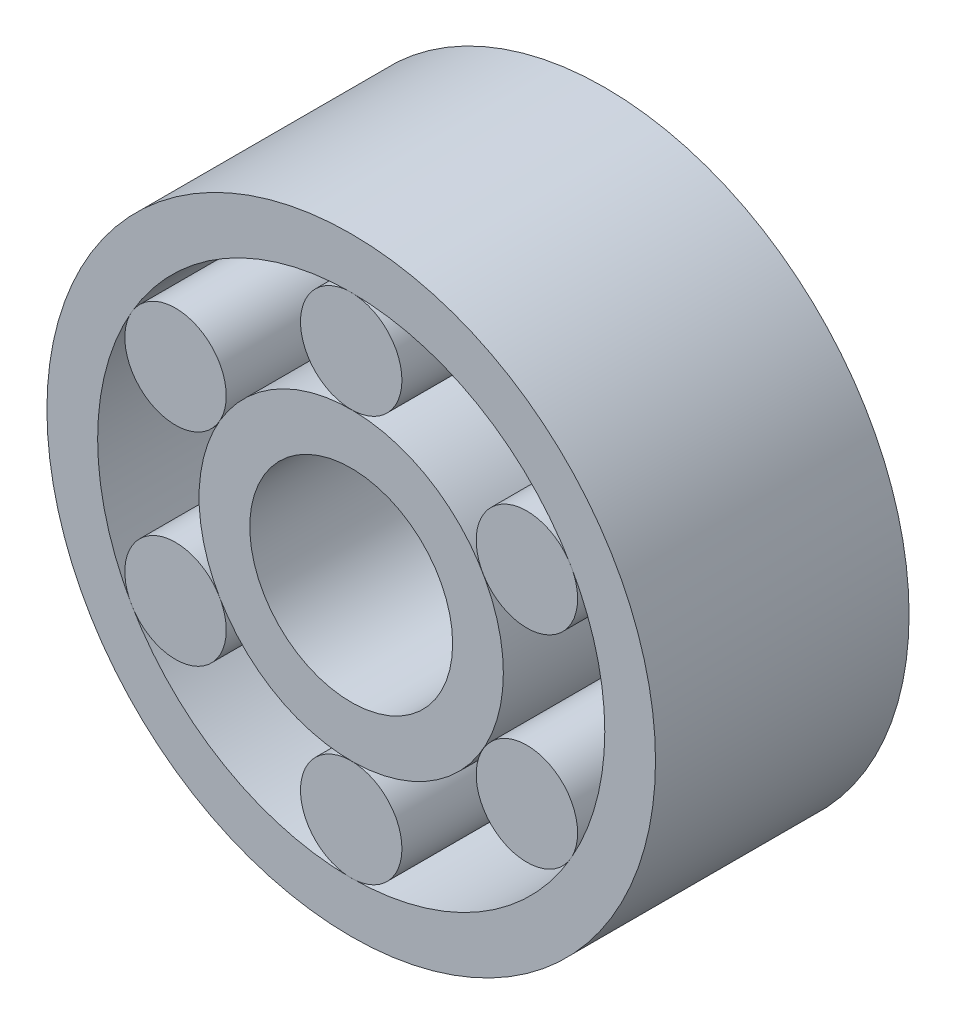
from build123d import *

# Parameters (mm, degrees)
SKETCH_1_R        = 1.5
SKETCH_1_R_2      = 1
EXTRUDE_1_DEPTH   = 2.5
SKETCH_1_R_3      = 0.5
EXTRUDE_1_2_DEPTH = 2.5
SKETCH_1_R_4      = 3
SKETCH_1_R_5      = 2.5
EXTRUDE_1_3_DEPTH = 2.5
EXTRUDE_1_4_DEPTH = 2.5
EXTRUDE_1_5_DEPTH = 2.5
EXTRUDE_1_6_DEPTH = 2.5
EXTRUDE_1_7_DEPTH = 2.5
EXTRUDE_1_8_DEPTH = 2.5


with BuildPart() as part:
    # 草图1 → 凸台-拉伸1 (new body)
    with BuildSketch(Plane.XY):
        Circle(SKETCH_1_R)
        Circle(SKETCH_1_R_2, mode=Mode.SUBTRACT)
    extrude(amount=EXTRUDE_1_DEPTH)


with BuildPart() as body_2:
    # 草图1 → Extrude 1 2 (new body)
    with BuildSketch(Plane.XY):
        with Locations((0, 2)):
            Circle(SKETCH_1_R_3)
    extrude(amount=EXTRUDE_1_2_DEPTH)


with BuildPart() as body_3:
    # 草图1 → Extrude 1 3 (new body)
    with BuildSketch(Plane.XY):
        Circle(SKETCH_1_R_4)
        Circle(SKETCH_1_R_5, mode=Mode.SUBTRACT)
    extrude(amount=EXTRUDE_1_3_DEPTH)


with BuildPart() as body_4:
    # 草图1 → Extrude 1 4 (new body)
    with BuildSketch(Plane.XY):
        with Locations((-1.732050808, 1)):
            Circle(SKETCH_1_R_3)
    extrude(amount=EXTRUDE_1_4_DEPTH)


with BuildPart() as body_5:
    # 草图1 → Extrude 1 5 (new body)
    with BuildSketch(Plane.XY):
        with Locations((1.732050808, 1)):
            Circle(SKETCH_1_R_3)
    extrude(amount=EXTRUDE_1_5_DEPTH)


with BuildPart() as body_6:
    # 草图1 → Extrude 1 6 (new body)
    with BuildSketch(Plane.XY):
        with Locations((1.732050808, -1)):
            Circle(SKETCH_1_R_3)
    extrude(amount=EXTRUDE_1_6_DEPTH)


with BuildPart() as body_7:
    # 草图1 → Extrude 1 7 (new body)
    with BuildSketch(Plane.XY):
        with Locations((0, -2)):
            Circle(SKETCH_1_R_3)
    extrude(amount=EXTRUDE_1_7_DEPTH)


with BuildPart() as body_8:
    # 草图1 → Extrude 1 8 (new body)
    with BuildSketch(Plane.XY):
        with Locations((-1.732050808, -1)):
            Circle(SKETCH_1_R_3)
    extrude(amount=EXTRUDE_1_8_DEPTH)


solid = Compound([part.part, body_2.part, body_3.part, body_4.part, body_5.part, body_6.part, body_7.part, body_8.part])
